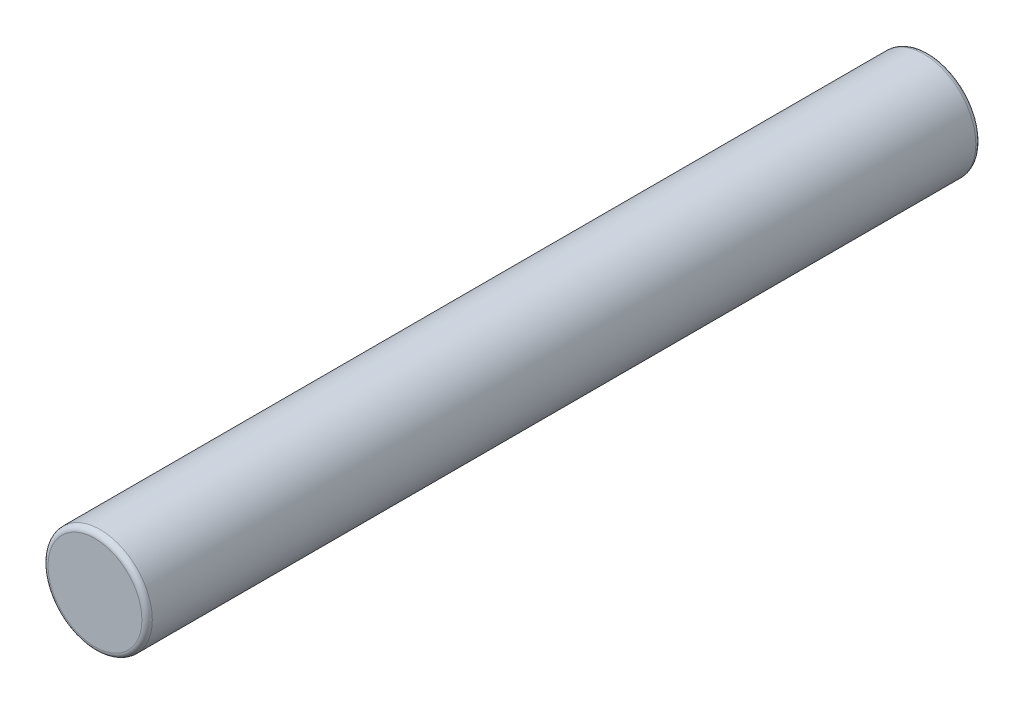
from build123d import *

# Parameters (mm, degrees)
SKETCH2_R           = 1
BOSS_EXTRUDE2_DEPTH = 16
FILLET1_R           = 0.1


with BuildPart() as part:
    # Sketch2 → Boss-Extrude2 (new body)
    with BuildSketch(Plane.XY):
        with Locations((-44.489039644, 13.731185075)):
            Circle(SKETCH2_R)
    extrude(amount=BOSS_EXTRUDE2_DEPTH)

    # Fillet1
    fillet1_edges = [part.edges().sort_by_distance(p)[0] for p in [
        (-45.489039644, 13.731185075, 0),
        (-45.489039644, 13.731185075, 16),
    ]]
    fillet(fillet1_edges, radius=FILLET1_R)


solid = part.part
